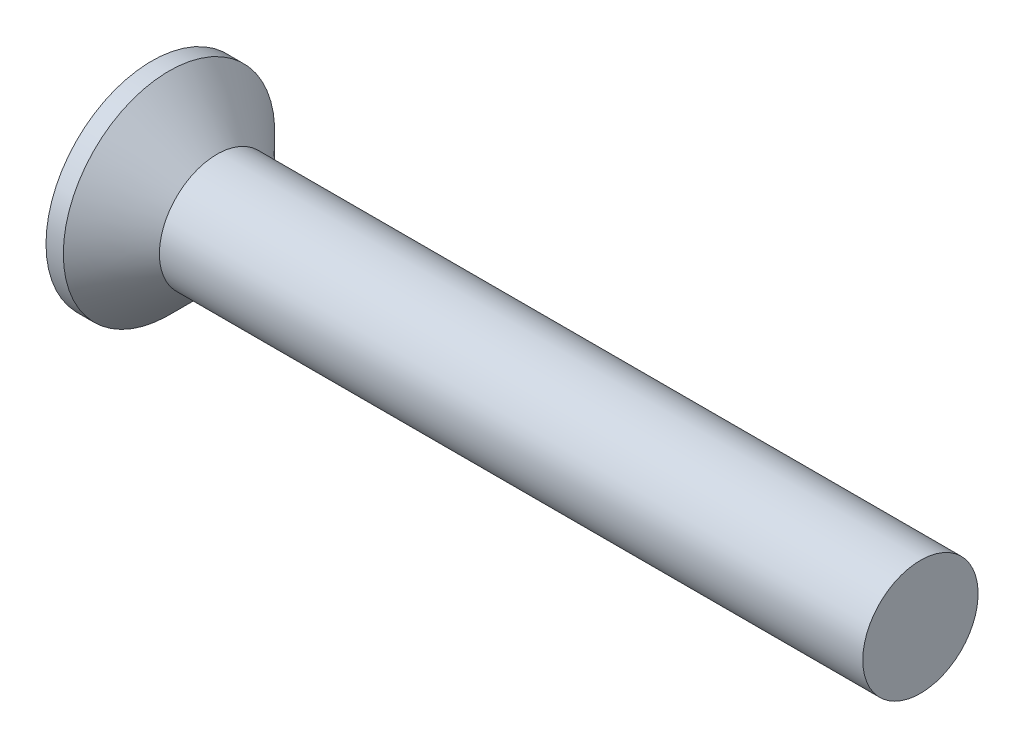
from build123d import *

# Parameters (mm, degrees)
SKETCH3_W         = 0.79
SKETCH3_H         = 3.1
SKETCH4_W         = 0.395
SKETCH4_H         = 0.395
CIRPATTERN1_COUNT = 2
CIRPATTERN1_ANGLE = 90


with BuildPart() as part:
    # BodySke → Base-Revolve (revolve)
    with BuildSketch(Plane.XY):
        Polygon((0, 0), (0, 2.75), (0.45, 2.75), (1.7, 1.5), (20, 1.5), (20, 0), align=None)
    revolve(axis=Axis((-6.35, 0, 0), (1, 0, 0)))

    # Sketch3 → Cross section 0
    with BuildSketch(Plane.ZY):
        Rectangle(SKETCH3_W, SKETCH3_H)
    # Sketch4 → Cross section 1
    with BuildSketch(Plane.ZY.offset(-2.08)):
        Rectangle(SKETCH4_W, SKETCH4_H)
    cross = loft(mode=Mode.SUBTRACT)

    # CirPattern1: Cross ×2 about axis
    cirpattern1_axis = Axis((0, 0, 0), (1, 0, 0))
    for i in range(1, CIRPATTERN1_COUNT):
        add(cross.rotate(cirpattern1_axis, i * CIRPATTERN1_ANGLE / (CIRPATTERN1_COUNT - 1)), mode=Mode.SUBTRACT)


solid = part.part
